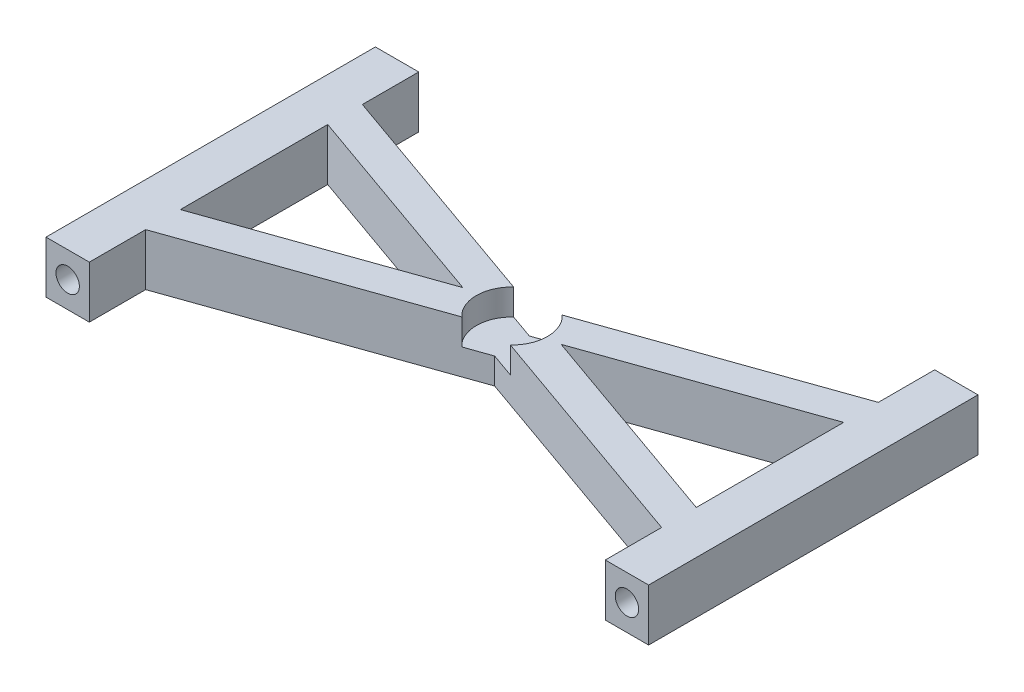
from build123d import *

# Parameters (mm, degrees)
BOSS_EXTRUDE1_DEPTH     = 6
SKETCH2_R               = 1.35
CUT_EXTRUDE1_DEPTH      = 39
ESQUISSE1_R             = 4.1
ENL_V_MAT_EXTRU_1_DEPTH = 3


with BuildPart() as part:
    # Sketch1 → Boss-Extrude1 (new body)
    with BuildSketch(Plane(origin=(0, 0, 0), x_dir=(1, 0, 0), z_dir=(0, 1, 0))):
        Polygon((2.5, 0), (0, 0), (0, 25), (2.5, 25), (2.5, 31.5), (-2.5, 31.5), (-2.5, -6.5), (2.5, -6.5), align=None)
        Polygon((0, 25), (0, 0), (2.5, 0), (2.5, 4), (2.5, 21), (2.5, 25), align=None)
        Polygon((32.26, 14.5), (2.5, 25), (2.5, 21), (26.591428571, 12.5), align=None)
        Polygon((26.591428571, 12.5), (32.26, 10.5), (37.928571429, 12.5), (32.26, 14.5), align=None)
        Polygon((32.26, 14.5), (37.928571429, 12.5), (62.02, 21), (62.02, 25), align=None)
        Polygon((2.5, 4), (2.5, 0), (32.26, 10.5), (26.591428571, 12.5), align=None)
        Polygon((32.26, 10.5), (62.02, 0), (62.02, 4), (37.928571429, 12.5), align=None)
        Polygon((62.02, 4), (62.02, 0), (64.52, 0), (64.52, 25), (62.02, 25), (62.02, 21), align=None)
        Polygon((64.52, 0), (62.02, 0), (62.02, -6.5), (67.02, -6.5), (67.02, 31.5), (62.02, 31.5), (62.02, 25), (64.52, 25), align=None)
    extrude(amount=BOSS_EXTRUDE1_DEPTH)

    # Sketch2 → Cut-Extrude1 (cut, through all)
    with BuildSketch(Plane(origin=(0, 0, -31.5), x_dir=(-1, 0, 0), z_dir=(0, 0, -1))):
        with Locations((0, 3)):
            Circle(SKETCH2_R)
        with Locations((-64.52, 3)):
            Circle(SKETCH2_R)
    extrude(amount=-CUT_EXTRUDE1_DEPTH, mode=Mode.SUBTRACT)

    # Esquisse1 → Enlèv. mat.-Extru.1 (cut)
    with BuildSketch(Plane(origin=(0, 6, 0), x_dir=(1, 0, 0), z_dir=(0, 1, 0))):
        with Locations((32.26, 12.5)):
            Circle(ESQUISSE1_R)
    extrude(amount=-ENL_V_MAT_EXTRU_1_DEPTH, mode=Mode.SUBTRACT)


solid = part.part
